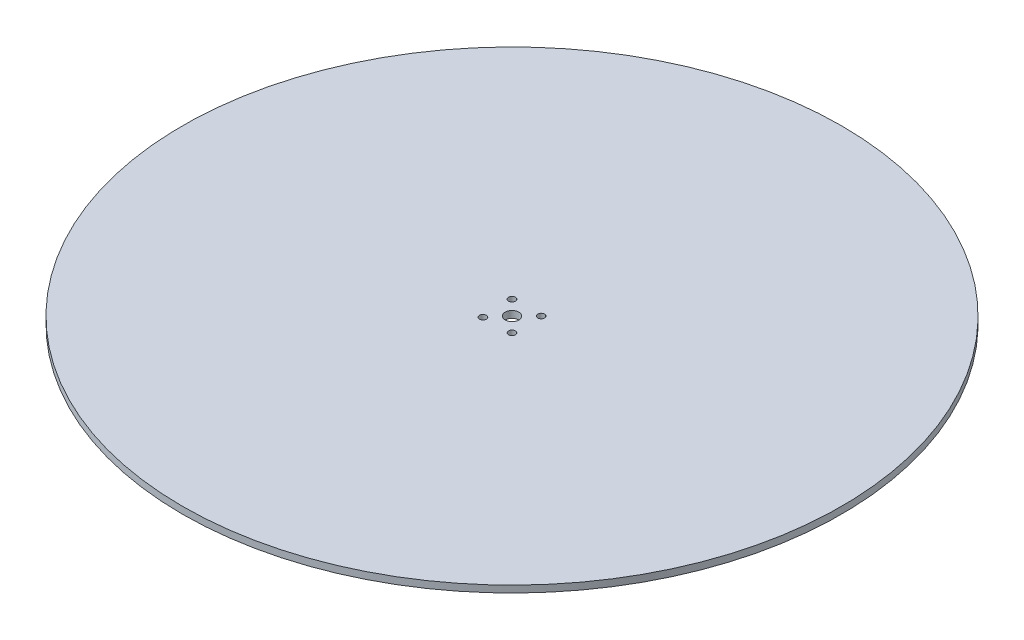
from build123d import *

# Parameters (mm, degrees)
SKETCH1_R           = 152.4
BOSS_EXTRUDE1_DEPTH = 3.175
CUT_EXTRUDE1_REACH  = 5.175
SKETCH2_R           = 3.175
SKETCH2_R_2         = 1.5875


with BuildPart() as part:
    # Sketch1 → Boss-Extrude1 (new body)
    with BuildSketch(Plane(origin=(0, 0, 0), x_dir=(1, 0, 0), z_dir=(0, 1, 0))):
        Circle(SKETCH1_R)
    extrude(amount=BOSS_EXTRUDE1_DEPTH)

    # Sketch2 → Cut-Extrude1 (cut, up to next)
    with BuildSketch(Plane(origin=(0, 3.175, 0), x_dir=(1, 0, 0), z_dir=(0, 1, 0)), mode=Mode.PRIVATE) as cut_extrude1_sk1:
        Circle(SKETCH2_R)
    cut_extrude1_tool1 = extrude(cut_extrude1_sk1.sketch, amount=-CUT_EXTRUDE1_REACH, mode=Mode.PRIVATE) & part.part
    add(cut_extrude1_tool1.solids().sort_by_distance((0, 3.175, 0))[0], mode=Mode.SUBTRACT)
    # Sketch2 → Cut-Extrude1 (cut, up to next)
    with BuildSketch(Plane(origin=(0, 3.175, 0), x_dir=(1, 0, 0), z_dir=(0, 1, 0)), mode=Mode.PRIVATE) as cut_extrude1_sk2:
        with Locations((6.735192091, 6.735192091)):
            Circle(SKETCH2_R_2)
    cut_extrude1_tool2 = extrude(cut_extrude1_sk2.sketch, amount=-CUT_EXTRUDE1_REACH, mode=Mode.PRIVATE) & part.part
    add(cut_extrude1_tool2.solids().sort_by_distance((6.735192, 3.175, -6.735192))[0], mode=Mode.SUBTRACT)
    # Sketch2 → Cut-Extrude1 (cut, up to next)
    with BuildSketch(Plane(origin=(0, 3.175, 0), x_dir=(1, 0, 0), z_dir=(0, 1, 0)), mode=Mode.PRIVATE) as cut_extrude1_sk3:
        with Locations((-6.735192091, 6.735192091)):
            Circle(SKETCH2_R_2)
    cut_extrude1_tool3 = extrude(cut_extrude1_sk3.sketch, amount=-CUT_EXTRUDE1_REACH, mode=Mode.PRIVATE) & part.part
    add(cut_extrude1_tool3.solids().sort_by_distance((-6.735192, 3.175, -6.735192))[0], mode=Mode.SUBTRACT)
    # Sketch2 → Cut-Extrude1 (cut, up to next)
    with BuildSketch(Plane(origin=(0, 3.175, 0), x_dir=(1, 0, 0), z_dir=(0, 1, 0)), mode=Mode.PRIVATE) as cut_extrude1_sk4:
        with Locations((-6.240150163, -7.19625951)):
            Circle(SKETCH2_R_2)
    cut_extrude1_tool4 = extrude(cut_extrude1_sk4.sketch, amount=-CUT_EXTRUDE1_REACH, mode=Mode.PRIVATE) & part.part
    add(cut_extrude1_tool4.solids().sort_by_distance((-6.24015, 3.175, 7.19626))[0], mode=Mode.SUBTRACT)
    # Sketch2 → Cut-Extrude1 (cut, up to next)
    with BuildSketch(Plane(origin=(0, 3.175, 0), x_dir=(1, 0, 0), z_dir=(0, 1, 0)), mode=Mode.PRIVATE) as cut_extrude1_sk5:
        with Locations((6.735192091, -6.735192091)):
            Circle(SKETCH2_R_2)
    cut_extrude1_tool5 = extrude(cut_extrude1_sk5.sketch, amount=-CUT_EXTRUDE1_REACH, mode=Mode.PRIVATE) & part.part
    add(cut_extrude1_tool5.solids().sort_by_distance((6.735192, 3.175, 6.735192))[0], mode=Mode.SUBTRACT)


solid = part.part
